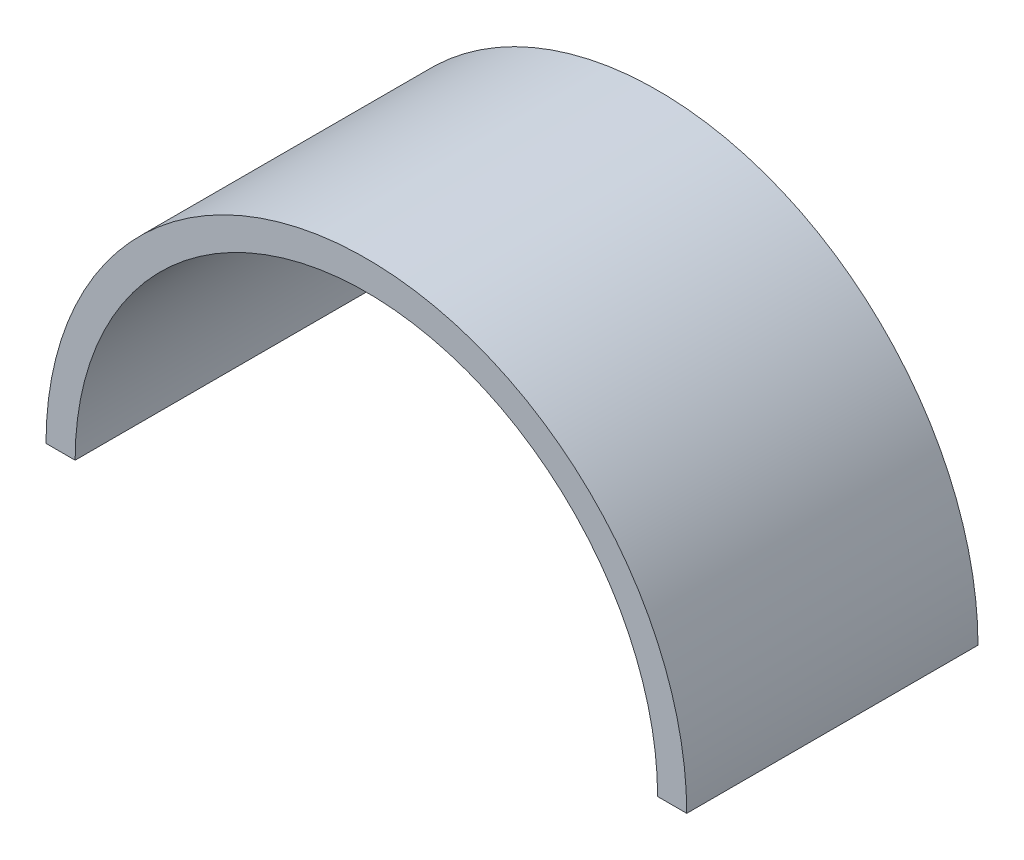
from build123d import *

# Parameters (mm, degrees)
BOSS_EXTRUDE1_DEPTH = 50
SKETCH2_R           = 1.6
CUT_EXTRUDE1_DEPTH  = 10


with BuildPart() as part:
    # Sketch1 → Boss-Extrude1 (new body)
    with BuildSketch(Plane.XY):
        with BuildLine():
            Line((55, 0), (50, 0))
            ThreePointArc((50, 0), (0, 50), (-50, 0))
            Line((-50, 0), (-55, 0))
            ThreePointArc((-55, 0), (0, 55), (55, 0))
        make_face()
    extrude(amount=BOSS_EXTRUDE1_DEPTH)

    # Sketch2 → Cut-Extrude1 (cut)
    with BuildSketch(Plane(origin=(0, 0, 0), x_dir=(-1, 0, 0), z_dir=(0, 0, -1))):
        with Locations((0, 52.5)):
            Circle(SKETCH2_R)
        with Locations((33.746349509, 40.217333264)):
            Circle(SKETCH2_R)
        with Locations((51.702407033, 9.116529328)):
            Circle(SKETCH2_R)
        with Locations((-51.702407033, 9.116529328)):
            Circle(SKETCH2_R)
        with Locations((-33.746349509, 40.217333264)):
            Circle(SKETCH2_R)
    extrude(amount=-CUT_EXTRUDE1_DEPTH, mode=Mode.SUBTRACT)


solid = part.part
